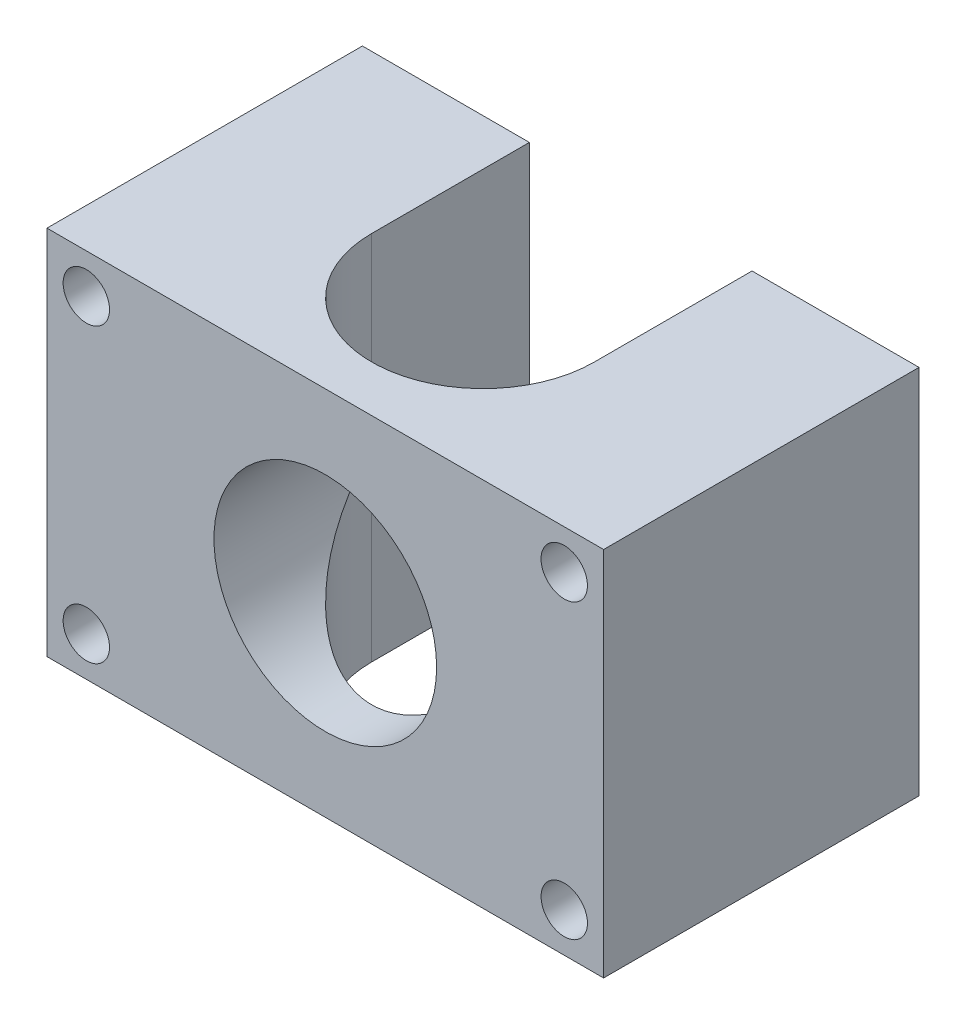
from build123d import *

# Parameters (mm, degrees)
SKETCH1_W           = 60
SKETCH1_H           = 40
BOSS_EXTRUDE1_DEPTH = 34
CUT_EXTRUDE1_DEPTH  = 40
SKETCH3_R           = 12
CUT_EXTRUDE2_DEPTH  = 40
SKETCH4_R           = 2.5
CUT_EXTRUDE3_DEPTH  = 40


with BuildPart() as part:
    # Sketch1 → Boss-Extrude1 (new body)
    with BuildSketch(Plane.XY):
        with Locations((30, 20)):
            Rectangle(SKETCH1_W, SKETCH1_H)
    extrude(amount=BOSS_EXTRUDE1_DEPTH)

    # Sketch2 → Cut-Extrude1 (cut)
    with BuildSketch(Plane.XZ):
        with BuildLine():
            ThreePointArc((42, 17), (30, 29), (18, 17))
            Line((18, 17), (18, 0))
            Line((18, 0), (42, 0))
            Line((42, 0), (42, 17))
        make_face()
    extrude(amount=-CUT_EXTRUDE1_DEPTH, mode=Mode.SUBTRACT)

    # Sketch3 → Cut-Extrude2 (cut)
    with BuildSketch(Plane.XY.offset(34)):
        with Locations((30, 20)):
            Circle(SKETCH3_R)
    extrude(amount=-CUT_EXTRUDE2_DEPTH, mode=Mode.SUBTRACT)

    # Sketch4 → Cut-Extrude3 (cut)
    with BuildSketch(Plane.XY.offset(34)):
        with Locations((55.757359313, 4.242640687)):
            Circle(SKETCH4_R)
        with Locations((4.242640687, 4.242640687)):
            Circle(SKETCH4_R)
        with Locations((55.757359313, 35.757359313)):
            Circle(SKETCH4_R)
        with Locations((4.242640687, 35.757359313)):
            Circle(SKETCH4_R)
    extrude(amount=-CUT_EXTRUDE3_DEPTH, mode=Mode.SUBTRACT)


solid = part.part
